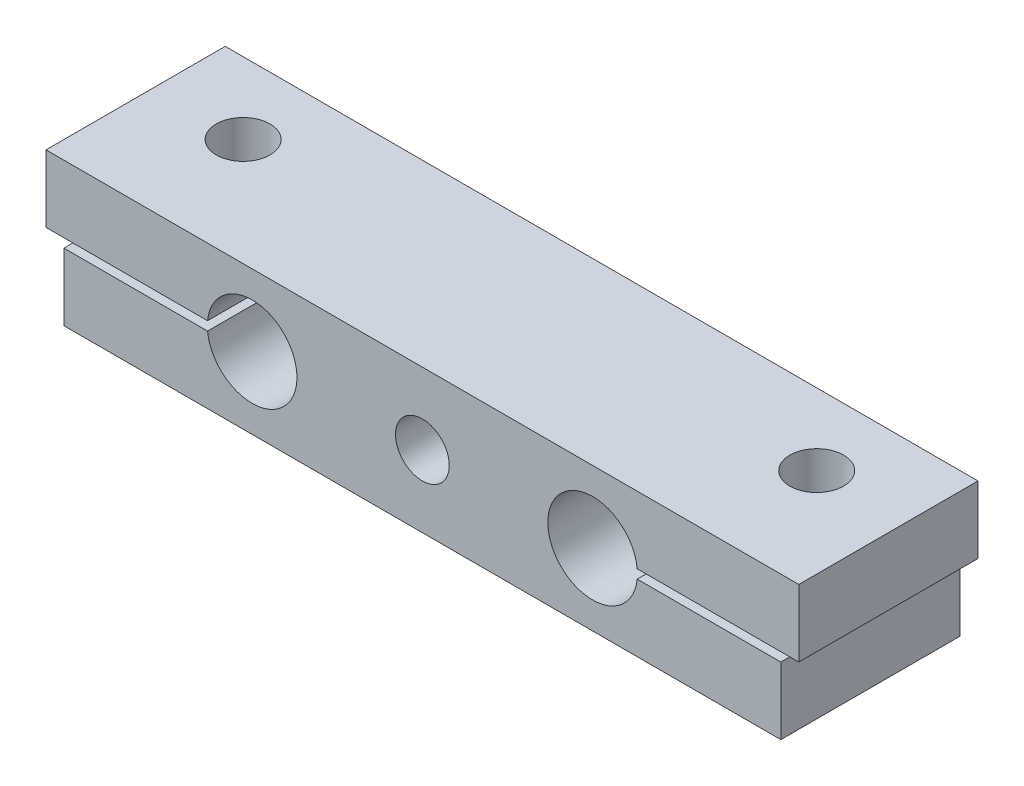
from build123d import *

# Parameters (mm, degrees)
BOSS_EXTRUDE1_DEPTH        = 10
M3X0_5_TAPPED_HOLE1_D      = 2.5
M3X0_5_TAPPED_HOLE1_DEPTH  = 3.74999984
M3X0_5_TAPPED_HOLE2_D      = 3
F_3_0MM_DOWEL_HOLE1_REACH  = 40.325
F_3_0MM_DOWEL_HOLE1_BORE_R = 1.5


with BuildPart() as part:
    # Sketch1 → Boss-Extrude1 (new body)
    with BuildSketch(Plane.XY):
        with BuildLine():
            Line((-19.997736867, 0.25), (-11.98520546, 0.25))
            ThreePointArc((-11.98520546, 0.25), (-6.997736867, 0), (-11.98520546, -0.25))
            Line((-11.98520546, -0.25), (-20, -0.25))
            Line((-20, -0.25), (-19.997736867, -3.99999984))
            Line((-19.997736867, -3.99999984), (19.997736867, -3.99999984))
            Line((19.997736867, -3.99999984), (19.997736867, -0.25))
            Line((19.997736867, -0.25), (11.98520546, -0.25))
            ThreePointArc((11.98520546, -0.25), (6.997736867, 0), (11.98520546, 0.25))
            Line((11.98520546, 0.25), (19.997736867, 0.25))
            Line((19.997736867, 0.25), (20.997736867, 0.25))
            Line((20.997736867, 0.25), (20.997736867, 3.99999984))
            Line((20.997736867, 3.99999984), (20.002263133, 3.99999984))
            Line((20.002263133, 3.99999984), (-19.997736867, 3.99999984))
            Line((-19.997736867, 3.99999984), (-20.997736867, 3.99999984))
            Line((-20.997736867, 3.99999984), (-20.997736867, 0.25))
            Line((-20.997736867, 0.25), (-19.997736867, 0.25))
        make_face()
    extrude(amount=BOSS_EXTRUDE1_DEPTH)

    # M3x0.5 Tapped Hole1
    with Locations(Plane(origin=(-16, -3.99999984, 4), x_dir=(-1, 0, 0), z_dir=(0, -1, 0))):
        with Locations((0, 0), (-32, 0)):
            Hole(M3X0_5_TAPPED_HOLE1_D / 2, depth=M3X0_5_TAPPED_HOLE1_DEPTH)

    # M3x0.5 Tapped Hole2 (through all)
    with Locations(Plane.XY.offset(10)):
        with Locations((0, 0)):
            Hole(M3X0_5_TAPPED_HOLE2_D / 2)

    # Ø3.0mm Dowel Hole1 bore (on position points) → Ø3.0mm Dowel Hole1 (cut, up to next)
    with BuildSketch(Plane(origin=(16, 3.99999984, 4), x_dir=(0, 0, 1), z_dir=(0, 1, 0)), mode=Mode.PRIVATE) as f_3_0mm_dowel_hole1_sk1:
        Circle(F_3_0MM_DOWEL_HOLE1_BORE_R)
    f_3_0mm_dowel_hole1_tool1 = extrude(f_3_0mm_dowel_hole1_sk1.sketch, amount=-F_3_0MM_DOWEL_HOLE1_REACH, mode=Mode.PRIVATE) & part.part
    # Ø3.0mm Dowel Hole1 bore (on position points) → Ø3.0mm Dowel Hole1 (cut, up to next)
    with BuildSketch(Plane(origin=(16, 3.99999984, 4), x_dir=(0, 0, 1), z_dir=(0, 1, 0)), mode=Mode.PRIVATE) as f_3_0mm_dowel_hole1_sk2:
        with Locations((0, -32)):
            Circle(F_3_0MM_DOWEL_HOLE1_BORE_R)
    f_3_0mm_dowel_hole1_tool2 = extrude(f_3_0mm_dowel_hole1_sk2.sketch, amount=-F_3_0MM_DOWEL_HOLE1_REACH, mode=Mode.PRIVATE) & part.part
    add(f_3_0mm_dowel_hole1_tool1.solids().sort_by_distance((16, 4, 4))[0], mode=Mode.SUBTRACT)
    add(f_3_0mm_dowel_hole1_tool2.solids().sort_by_distance((-16, 4, 4))[0], mode=Mode.SUBTRACT)


solid = part.part
